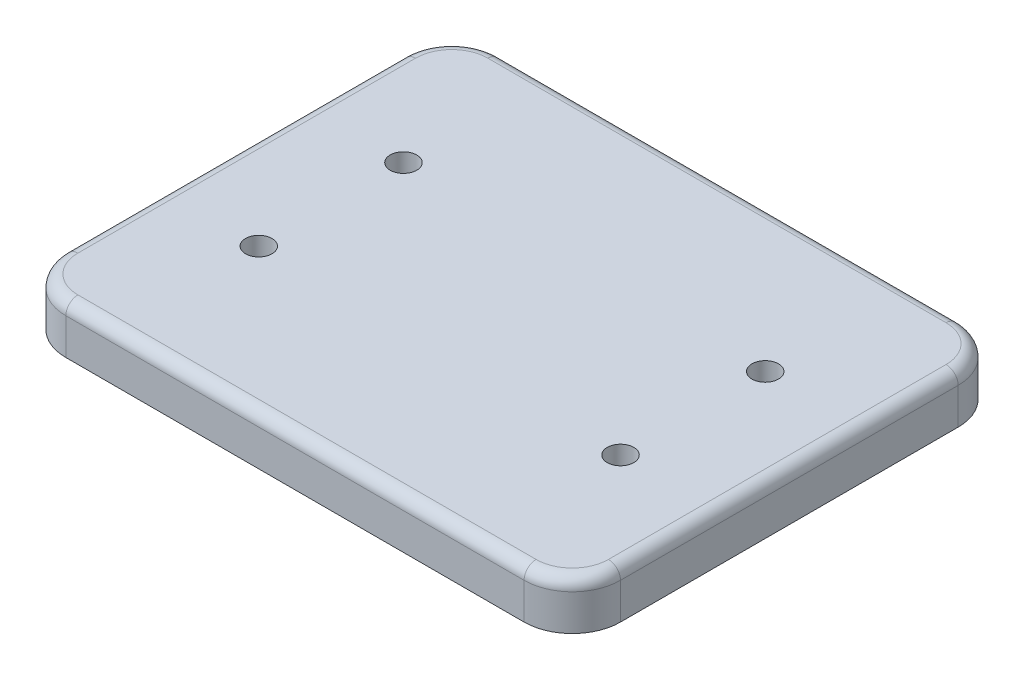
from build123d import *

# Parameters (mm, degrees)
SKETCH1_W              = 230
SKETCH1_H              = 180
BASE_DEPTH             = 20
R20_FILLETS_R          = 20
R5_FILLETS_R           = 5
BOLT_HOLES_D           = 11
BOLT_HOLES_DEPTH       = 20
BOLT_HOLES_CBORE_D     = 18
BOLT_HOLES_CBORE_DEPTH = 11
BOLT_HOLES_TIP         = 3.304733405


with BuildPart() as part:
    # Sketch1 → Base (new body)
    with BuildSketch(Plane(origin=(0, 0, 0), x_dir=(1, 0, 0), z_dir=(0, 1, 0))):
        Rectangle(SKETCH1_W, SKETCH1_H)
    extrude(amount=BASE_DEPTH)

    # R20 Fillets
    r20_fillets_edges = [part.edges().sort_by_distance(p)[0] for p in [
        (115, 10, 90),
        (-115, 10, 90),
        (-115, 10, -90),
        (115, 10, -90),
    ]]
    fillet(r20_fillets_edges, radius=R20_FILLETS_R)

    # R5 Fillets
    r5_fillets_edges = [part.edges().sort_by_distance(p)[0] for p in [
        (0, 20, 90),
        (-115, 20, 0),
        (115, 20, 0),
        (0, 20, -90),
        (109.142135624, 20, 84.142135624),
        (109.142135624, 20, -84.142135624),
        (-109.142135624, 20, -84.142135624),
        (-109.142135624, 20, 84.142135624),
    ]]
    fillet(r5_fillets_edges, radius=R5_FILLETS_R)

    # Bolt Holes
    with Locations(Plane(origin=(0, 0, 0), x_dir=(-1, 0, 0), z_dir=(0, -1, 0))):
        with Locations((-75, 30), (-75, -30), (75, -30), (75, 30)):
            CounterBoreHole(BOLT_HOLES_D / 2, BOLT_HOLES_CBORE_D / 2, BOLT_HOLES_CBORE_DEPTH, depth=BOLT_HOLES_DEPTH)
            with Locations((0, 0, -(BOLT_HOLES_DEPTH + BOLT_HOLES_TIP / 2))):  # 118° drill point
                Cone(0, BOLT_HOLES_D / 2, BOLT_HOLES_TIP, mode=Mode.SUBTRACT)


solid = part.part
